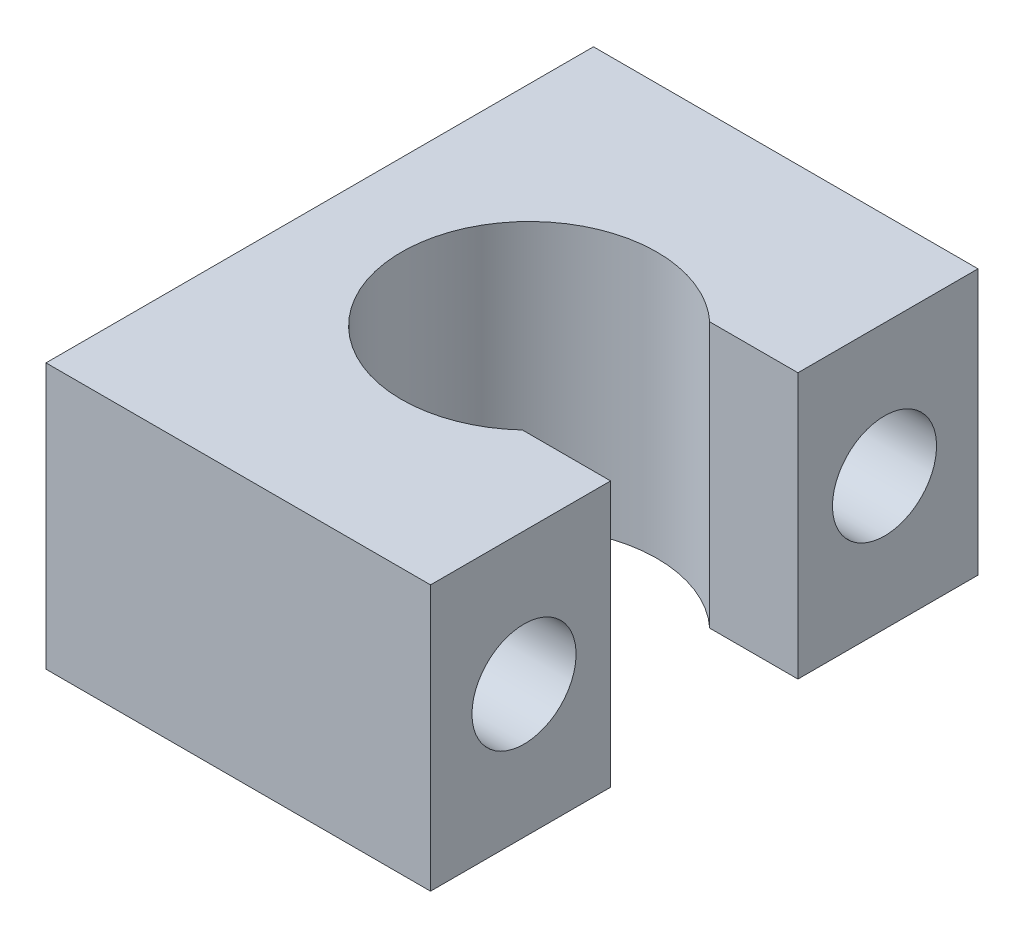
from build123d import *

# Parameters (mm, degrees)
SKETCH1_W           = 20.32
SKETCH1_H           = 28.93
BOSS_EXTRUDE1_DEPTH = 14.02
CUT_EXTRUDE1_DEPTH  = 15.02
SKETCH3_R           = 2.75
CUT_EXTRUDE2_DEPTH  = 21.32


with BuildPart() as part:
    # Sketch1 → Boss-Extrude1 (new body)
    with BuildSketch(Plane(origin=(0, 0, 0), x_dir=(1, 0, 0), z_dir=(0, 1, 0))):
        Rectangle(SKETCH1_W, SKETCH1_H)
    extrude(amount=BOSS_EXTRUDE1_DEPTH)

    # Sketch2 → Cut-Extrude1 (cut, through all)
    with BuildSketch(Plane(origin=(0, 14.02, 0), x_dir=(1, 0, 0), z_dir=(0, 1, 0))):
        with BuildLine():
            Line((10.16, -4.95), (5.499117562, -4.95))
            ThreePointArc((5.499117562, -4.95), (-5.84, 0), (5.499117562, 4.95))
            Line((5.499117562, 4.95), (10.16, 4.95))
            Line((10.16, 4.95), (10.16, -4.95))
        make_face()
    extrude(amount=-CUT_EXTRUDE1_DEPTH, mode=Mode.SUBTRACT)

    # Sketch3 → Cut-Extrude2 (cut, through all)
    with BuildSketch(Plane.ZY.offset(10.16)):
        with Locations((9.525, 7.01)):
            Circle(SKETCH3_R)
        with Locations((-9.525, 7.01)):
            Circle(SKETCH3_R)
    extrude(amount=-CUT_EXTRUDE2_DEPTH, mode=Mode.SUBTRACT)


solid = part.part
